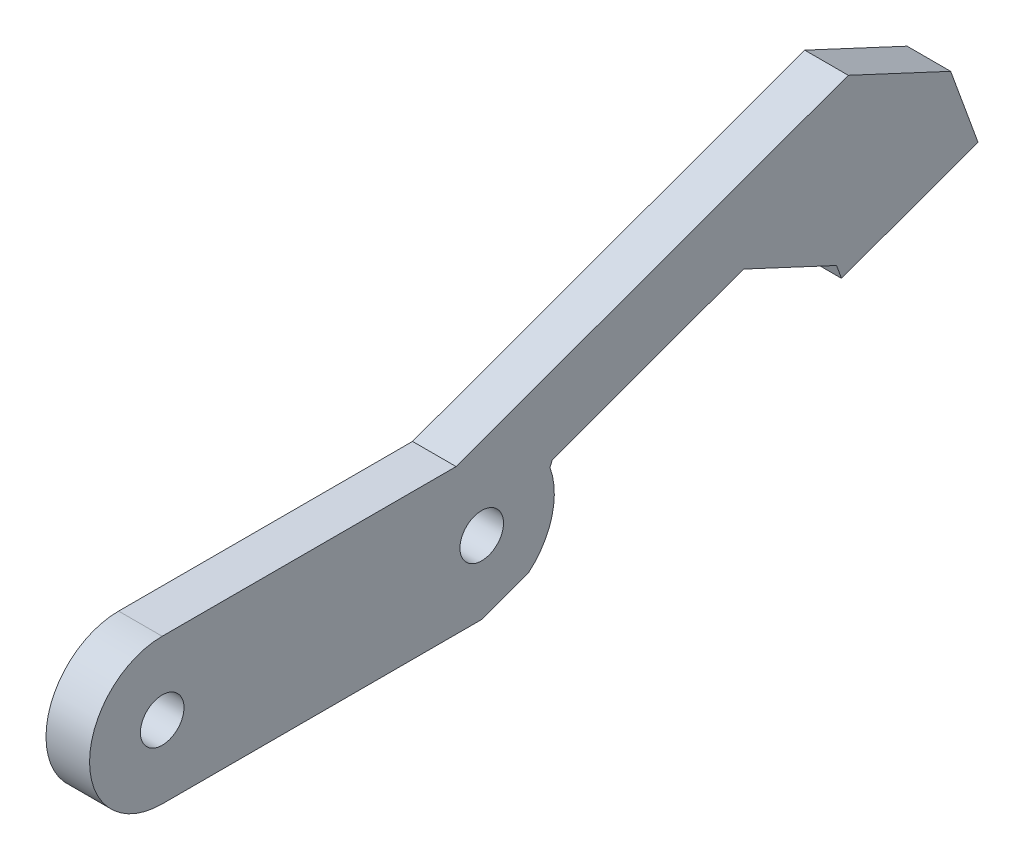
from build123d import *

# Parameters (mm, degrees)
SKETCH1_R           = 5
SKETCH1_R_2         = 1.5
BOSS_EXTRUDE1_DEPTH = 3
BOSS_EXTRUDE2_DEPTH = 3
CUT_EXTRUDE1_DEPTH  = 3
CUT_EXTRUDE2_DEPTH  = 4


with BuildPart() as part:
    # Sketch1 → Boss-Extrude1 (new body)
    with BuildSketch(Plane(origin=(0, 0, 0), x_dir=(0, 0, -1), z_dir=(1, 0, 0))):
        with Locations((5, 5)):
            Circle(SKETCH1_R)
        with Locations((5, 5)):
            Circle(SKETCH1_R_2, mode=Mode.SUBTRACT)
        with BuildLine():
            ThreePointArc((10, 5), (8.535533906, 1.464466094), (5, 0))
            Line((5, 0), (27, 0))
            ThreePointArc((27, 0), (22, 5), (27, 10))
            Line((27, 10), (5, 10))
            ThreePointArc((5, 10), (8.535533906, 8.535533906), (10, 5))
        make_face()
        with Locations((27, 5)):
            Circle(SKETCH1_R)
        with Locations((27, 5)):
            Circle(SKETCH1_R_2, mode=Mode.SUBTRACT)
    extrude(amount=BOSS_EXTRUDE1_DEPTH)

    # Sketch2 → Boss-Extrude2 (add)
    with BuildSketch(Plane(origin=(3, 0, 0), x_dir=(0, 0, -1), z_dir=(1, 0, 0))):
        with BuildLine():
            ThreePointArc((27, 10), (29.863119288, 9.099091112), (31.69447473, 6.721019177))
            Line((31.69447473, 6.721019177), (31.867747629, 7.092604107))
            Line((31.867747629, 7.092604107), (45.02344432, 11.880886114))
            Line((45.02344432, 11.880886114), (51.43200814, 8.892523726))
            Line((51.43200814, 8.892523726), (60.828934348, 12.31272516))
            Line((60.828934348, 12.31272516), (57.408732915, 21.709651368))
            Line((57.408732915, 21.709651368), (25.236730193, 10))
            Line((25.236730193, 10), (27, 10))
        make_face()
        Polygon((60.828934348, 12.31272516), (51.43200814, 8.892523726), (51.774028284, 7.952831106), (61.170954492, 11.373032539), align=None)
    extrude(amount=-BOSS_EXTRUDE2_DEPTH)

    # Sketch3 → Cut-Extrude1 (cut)
    with BuildSketch(Plane(origin=(3, 0, 0), x_dir=(0, 0, -1), z_dir=(1, 0, 0))):
        with BuildLine():
            ThreePointArc((27, 0), (28.710100717, 0.301536896), (30.213938048, 1.169777784))
            Line((30.213938048, 1.169777784), (27, 0))
        make_face()
    extrude(amount=-CUT_EXTRUDE1_DEPTH, mode=Mode.SUBTRACT)

    # Sketch4 → Cut-Extrude2 (cut, through all)
    with BuildSketch(Plane(origin=(3, 0, 0), x_dir=(0, 0, -1), z_dir=(1, 0, 0))):
        Polygon((57.408732915, 21.709651368), (52.240423501, 19.828540579), (59.289843703, 16.541341953), align=None)
    extrude(amount=-CUT_EXTRUDE2_DEPTH, mode=Mode.SUBTRACT)


solid = part.part
